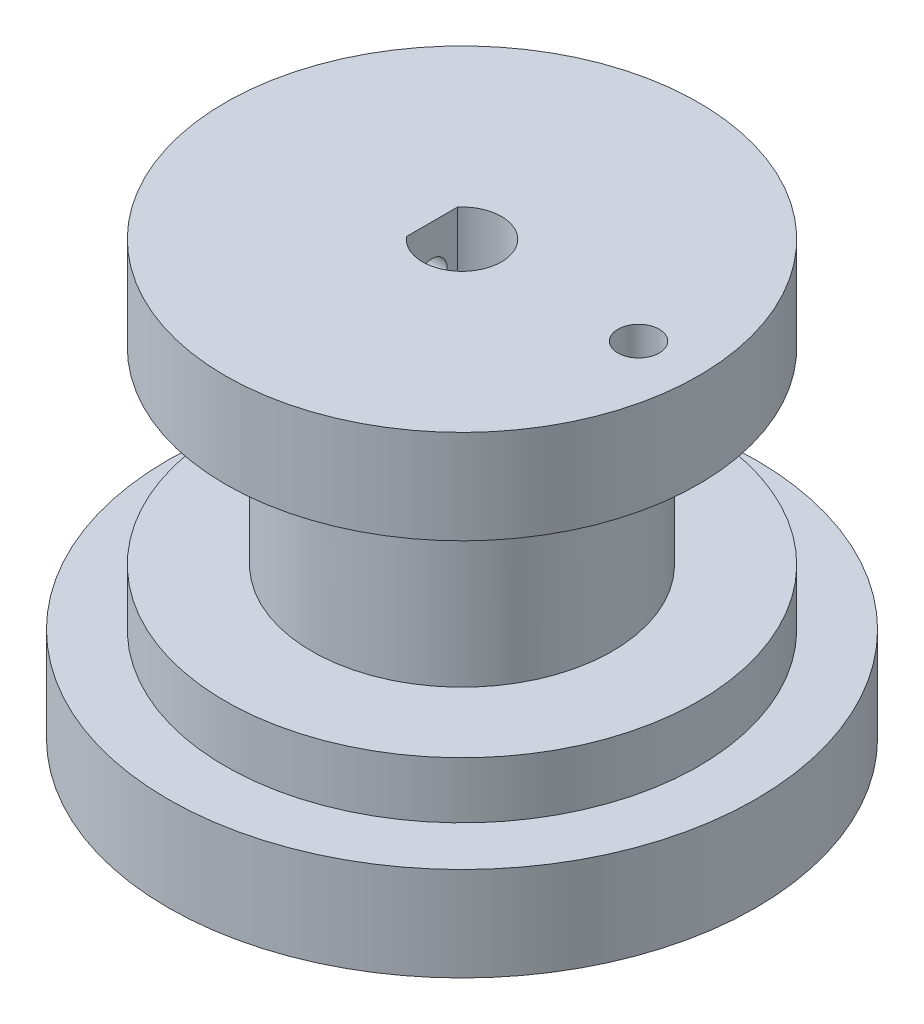
from build123d import *

# Parameters (mm, degrees)
SKETCH1_R                       = 8
BOSS_EXTRUDE1_DEPTH             = 10
SKETCH2_R                       = 12.6
BOSS_EXTRUDE2_DEPTH             = 3
SKETCH4_R                       = 1.5
CUT_EXTRUDE4_DEPTH              = 13
SKETCH3_R                       = 12.6
BOSS_EXTRUDE4_DEPTH             = 5
SKETCH5_R                       = 2.1
CUT_EXTRUDE5_DEPTH              = 19
SKETCH6_W                       = 1
SKETCH6_H                       = 4.89371283
BOSS_EXTRUDE5_DEPTH             = 8
TAP_DRILL_FOR_M2X0_4_TAP1_D     = 1.6
TAP_DRILL_FOR_M2X0_4_TAP1_DEPTH = 16
TAP_DRILL_FOR_M2X0_4_TAP1_TIP   = 0.480688495
SKETCH16_R                      = 15.644014
BOSS_EXTRUDE6_DEPTH             = 5
SKETCH17_R                      = 2.1
CUT_EXTRUDE6_DEPTH              = 5
SKETCH18_R                      = 1.1
CUT_EXTRUDE9_DEPTH              = 9.0000001
SKETCH19_R                      = 1.1
CUT_EXTRUDE10_DEPTH             = 10


with BuildPart() as part:
    # Sketch1 → Boss-Extrude1 (new body)
    with BuildSketch(Plane(origin=(0, 0, 0), x_dir=(1, 0, 0), z_dir=(0, 1, 0))):
        Circle(SKETCH1_R)
    extrude(amount=BOSS_EXTRUDE1_DEPTH)

    # Sketch2 → Boss-Extrude2 (add)
    with BuildSketch(Plane.XZ):
        Circle(SKETCH2_R)
    extrude(amount=BOSS_EXTRUDE2_DEPTH)

    # Sketch4 → Cut-Extrude4 (cut)
    with BuildSketch(Plane(origin=(0, 10, 0), x_dir=(1, 0, 0), z_dir=(0, 1, 0))):
        Circle(SKETCH4_R)
    extrude(amount=-CUT_EXTRUDE4_DEPTH, mode=Mode.SUBTRACT)

    # Sketch3 → Boss-Extrude4 (add)
    with BuildSketch(Plane(origin=(0, 10, 0), x_dir=(1, 0, 0), z_dir=(0, 1, 0))):
        Circle(SKETCH3_R)
    extrude(amount=BOSS_EXTRUDE4_DEPTH)

    # Sketch5 → Cut-Extrude5 (cut, through all)
    with BuildSketch(Plane(origin=(0, 15, 0), x_dir=(1, 0, 0), z_dir=(0, 1, 0))):
        Circle(SKETCH5_R)
    extrude(amount=-CUT_EXTRUDE5_DEPTH, mode=Mode.SUBTRACT)

    # Sketch6 → Boss-Extrude5 (add)
    with BuildSketch(Plane(origin=(0, 15, 0), x_dir=(1, 0, 0), z_dir=(0, 1, 0))):
        with Locations((-2.1, 0)):
            Rectangle(SKETCH6_W, SKETCH6_H)
    extrude(amount=-BOSS_EXTRUDE5_DEPTH)

    # Tap Drill for M2x0.4 Tap1
    with Locations(Plane.ZY.offset(12.6)):
        with Locations((0, 12.5)):
            Hole(TAP_DRILL_FOR_M2X0_4_TAP1_D / 2, depth=TAP_DRILL_FOR_M2X0_4_TAP1_DEPTH)
            with Locations((0, 0, -(TAP_DRILL_FOR_M2X0_4_TAP1_DEPTH + TAP_DRILL_FOR_M2X0_4_TAP1_TIP / 2))):  # 118° drill point
                Cone(0, TAP_DRILL_FOR_M2X0_4_TAP1_D / 2, TAP_DRILL_FOR_M2X0_4_TAP1_TIP, mode=Mode.SUBTRACT)

    # Sketch16 → Boss-Extrude6 (add)
    with BuildSketch(Plane(origin=(0, -3, 0), x_dir=(-1, 0, 0), z_dir=(0, -1, 0))):
        Circle(SKETCH16_R)
    extrude(amount=BOSS_EXTRUDE6_DEPTH)

    # Sketch17 → Cut-Extrude6 (cut)
    with BuildSketch(Plane(origin=(0, -8, 0), x_dir=(-1, 0, 0), z_dir=(0, -1, 0))):
        Circle(SKETCH17_R)
    extrude(amount=-CUT_EXTRUDE6_DEPTH, mode=Mode.SUBTRACT)

    # Sketch18 → Cut-Extrude9 (cut, through all)
    with BuildSketch(Plane(origin=(0, 0, 0), x_dir=(1, 0, 0), z_dir=(0, 1, 0))):
        with Locations((-9.4, 0)):
            Circle(SKETCH18_R)
    extrude(amount=-CUT_EXTRUDE9_DEPTH, mode=Mode.SUBTRACT)

    # Sketch19 → Cut-Extrude10 (cut)
    with BuildSketch(Plane(origin=(0, 10, 0), x_dir=(-1, 0, 0), z_dir=(0, -1, 0))):
        with Locations((-9.4, 0)):
            Circle(SKETCH19_R)
    extrude(amount=-CUT_EXTRUDE10_DEPTH, mode=Mode.SUBTRACT)


solid = part.part
